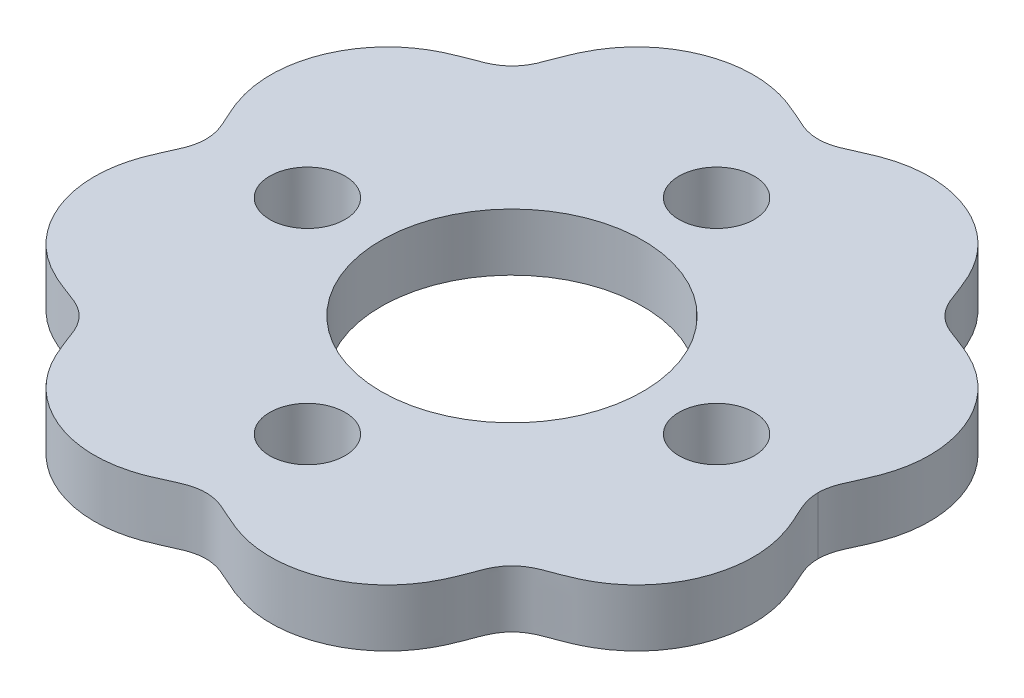
from build123d import *

# Parameters (mm, degrees)
BOSS_EXTRUDE1_DEPTH = 7
SKETCH3_R           = 16
SKETCH3_R_2         = 4.5
CUT_EXTRUDE1_DEPTH  = 7
CUT_EXTRUDE2_DEPTH  = 7
SKETCH5_R           = 4.6
SKETCH5_R_2         = 4.5
CUT_EXTRUDE3_DEPTH  = 7


with BuildPart() as part:
    # Sketch2 → Boss-Extrude1 (new body)
    with BuildSketch(Plane(origin=(0, 0, 0), x_dir=(1, 0, 0), z_dir=(0, 1, 0))):
        with BuildLine():
            add(Edge.make_bspline(
                [(37.500000178, 0), (37.500001348, -0.153650042), (37.516723117, -0.585734713), (37.60134551, -1.155885936), (37.799451038, -1.845132779), (38.055257689, -2.50061582), (38.284413658, -3.01884437), (38.547573645, -3.586057627), (38.834335204, -4.207231283), (39.213023964, -5.071386775), (39.642902809, -6.195484546), (40.034770345, -7.545626157), (40.309114863, -9.129071904), (40.402480997, -10.733442687), (40.292330227, -12.739242447), (39.800709206, -15.115411572), (38.875008006, -17.372282299), (37.550500891, -19.416826213), (36.201869244, -20.937061223), (34.991297456, -22.022332107), (33.664442598, -22.961820777), (32.418877976, -23.648429526), (31.307176029, -24.144813461), (30.415442254, -24.492540623), (29.760772524, -24.733252947), (29.159260868, -24.953726937), (28.615153012, -25.166050116), (27.968227921, -25.455751973), (27.242450172, -25.869161743), (26.486758972, -26.478530797), (25.788934233, -27.338578085), (25.333439826, -28.199550113), (25.02084924, -28.978917238), (24.756184284, -29.69717513), (24.520071708, -30.342148991), (24.176798097, -31.229963234), (23.685673389, -32.343953643), (23.006023391, -33.593318677), (22.074382722, -34.925670234), (20.99628636, -36.142619362), (19.483992231, -37.500137581), (17.436434568, -38.843473511), (15.165772212, -39.787003781), (12.765640508, -40.290729235), (10.727941267, -40.403684264), (9.098120231, -40.306732746), (7.490297544, -40.023060283), (6.12050869, -39.618509318), (4.980859334, -39.175936442), (3.981084292, -38.733166074), (3.107747272, -38.323212218), (2.16284156, -37.896233325), (1.102684883, -37.568652762), (-4e-09, -37.451718585), (-1.102684874, -37.568652759), (-2.162841573, -37.896233332), (-3.107747248, -38.323212203), (-3.981084328, -38.733166098), (-4.980859269, -39.175936398), (-6.120508811, -39.6185094), (-7.490297349, -40.023060149), (-9.098120503, -40.306732933), (-10.727940878, -40.403683996), (-12.765641194, -40.290729708), (-15.165770912, -39.787002885), (-17.436436591, -38.843474905), (-19.48398961, -37.500135775), (-20.996290415, -36.142622155), (-22.074374394, -34.925664496), (-23.006039129, -33.59332952), (-23.685647307, -32.343935674), (-24.176838549, -31.229991103), (-24.570729586, -30.210893235), (-24.899588849, -29.300399238), (-25.267416458, -28.324512461), (-25.788900803, -27.338555053), (-26.486780724, -26.478545782), (-27.242436428, -25.869152274), (-27.968236735, -25.455758045), (-28.615147496, -25.166046316), (-29.159264206, -24.953729236), (-29.760770668, -24.733251668), (-30.415443148, -24.492541238), (-31.307175489, -24.144813089), (-32.41887831, -23.648429756), (-33.6644424, -22.96182064), (-34.99129756, -22.022332179), (-36.201869193, -20.937061188), (-37.550500924, -19.416826235), (-38.875007981, -17.372282282), (-39.800709222, -15.115411584), (-40.292330218, -12.739242441), (-40.402481002, -10.733442691), (-40.309114859, -9.129071901), (-40.034770347, -7.545626159), (-39.642902807, -6.195484545), (-39.213023965, -5.071386776), (-38.834335204, -4.207231283), (-38.547573646, -3.586057627), (-38.284413658, -3.01884437), (-38.055257689, -2.50061582), (-37.799451038, -1.845132779), (-37.60134551, -1.155885936), (-37.516723117, -0.585734713), (-37.500001348, -0.153650042), (-37.500000178, 0)],
                knots=[0.119900748, 0.119900748, 0.119900748, 0.119900748, 0.119900748, 0.123359436, 0.129627259, 0.132815238, 0.136003217, 0.139191195, 0.142379174, 0.14689104, 0.151402906, 0.160426638, 0.169450869, 0.1784751, 0.187499512, 0.196523925, 0.214572937, 0.232831382, 0.241960244, 0.251089107, 0.260218415, 0.269347723, 0.278476117, 0.283040314, 0.287604511, 0.290890352, 0.294176194, 0.297462035, 0.300747877, 0.306837966, 0.312927068, 0.319161334, 0.325493528, 0.328659626, 0.331825723, 0.336390118, 0.340954513, 0.350083302, 0.35921236, 0.368341418, 0.377470301, 0.386599184, 0.404857643, 0.423193135, 0.432360527, 0.441527919, 0.450695565, 0.459863212, 0.469030281, 0.473613816, 0.47819735, 0.484472892, 0.490748434, 0.496943117, 0.503056883, 0.509251566, 0.515527108, 0.52180265, 0.526386184, 0.530969719, 0.540136788, 0.549304435, 0.558472081, 0.567639473, 0.576806865, 0.595142357, 0.613400816, 0.622529699, 0.631658582, 0.64078764, 0.649916698, 0.659045487, 0.663609882, 0.668174277, 0.674506472, 0.680838666, 0.687072932, 0.693162034, 0.699252123, 0.702537965, 0.705823806, 0.709109648, 0.712395489, 0.716959686, 0.721523883, 0.730652277, 0.739781585, 0.748910893, 0.758039756, 0.767168618, 0.785427063, 0.803476075, 0.812500488, 0.8215249, 0.830549131, 0.839573362, 0.848597094, 0.85310896, 0.857620826, 0.860808805, 0.863996783, 0.867184762, 0.870372741, 0.876640564, 0.880099252, 0.880099252, 0.880099252, 0.880099252, 0.880099252], degree=4))
            add(Edge.make_bspline(
                [(37.500000178, 0), (37.500001348, 0.153650042), (37.516723117, 0.585734713), (37.60134551, 1.155885936), (37.799451038, 1.845132779), (38.055257689, 2.50061582), (38.284413658, 3.018844371), (38.547573645, 3.586057627), (38.834335204, 4.207231284), (39.213023964, 5.071386775), (39.642902809, 6.195484546), (40.034770345, 7.545626157), (40.309114863, 9.129071904), (40.402480997, 10.733442688), (40.292330227, 12.739242447), (39.800709205, 15.115411572), (38.875008006, 17.3722823), (37.550500891, 19.416826213), (36.201869244, 20.937061223), (34.991297456, 22.022332107), (33.664442598, 22.961820777), (32.418877976, 23.648429526), (31.307176029, 24.144813461), (30.415442254, 24.492540623), (29.760772524, 24.733252947), (29.159260868, 24.953726937), (28.615153012, 25.166050117), (27.968227921, 25.455751974), (27.242450172, 25.869161744), (26.486758972, 26.478530797), (25.788934233, 27.338578085), (25.333439826, 28.199550113), (25.02084924, 28.978917238), (24.756184284, 29.69717513), (24.520071708, 30.342148991), (24.176798097, 31.229963234), (23.685673389, 32.343953643), (23.006023391, 33.593318677), (22.074382722, 34.925670234), (20.99628636, 36.142619362), (19.483992231, 37.500137582), (17.436434568, 38.843473511), (15.165772212, 39.787003781), (12.765640508, 40.290729235), (10.727941267, 40.403684265), (9.098120231, 40.306732746), (7.490297544, 40.023060283), (6.12050869, 39.618509318), (4.980859334, 39.175936443), (3.981084292, 38.733166074), (3.107747271, 38.323212218), (2.162841559, 37.896233325), (1.102684882, 37.568652762), (-4e-09, 37.451718586), (-1.102684874, 37.568652759), (-2.162841573, 37.896233332), (-3.107747248, 38.323212203), (-3.981084328, 38.733166098), (-4.980859269, 39.175936399), (-6.120508811, 39.6185094), (-7.490297349, 40.023060149), (-9.098120503, 40.306732933), (-10.727940878, 40.403683996), (-12.765641194, 40.290729708), (-15.165770912, 39.787002885), (-17.436436591, 38.843474905), (-19.48398961, 37.500135776), (-20.996290415, 36.142622155), (-22.074374394, 34.925664496), (-23.006039129, 33.59332952), (-23.685647307, 32.343935674), (-24.176838549, 31.229991103), (-24.570729586, 30.210893235), (-24.899588849, 29.300399238), (-25.267416458, 28.324512461), (-25.788900803, 27.338555053), (-26.486780724, 26.478545782), (-27.242436428, 25.869152274), (-27.968236735, 25.455758045), (-28.615147496, 25.166046316), (-29.159264206, 24.953729236), (-29.760770668, 24.733251668), (-30.415443148, 24.492541238), (-31.307175489, 24.144813089), (-32.418878311, 23.648429756), (-33.6644424, 22.96182064), (-34.99129756, 22.022332179), (-36.201869193, 20.937061188), (-37.550500924, 19.416826235), (-38.875007981, 17.372282282), (-39.800709222, 15.115411584), (-40.292330218, 12.739242441), (-40.402481002, 10.733442691), (-40.309114859, 9.129071901), (-40.034770347, 7.545626159), (-39.642902807, 6.195484545), (-39.213023965, 5.071386776), (-38.834335204, 4.207231283), (-38.547573646, 3.586057627), (-38.284413658, 3.01884437), (-38.055257689, 2.50061582), (-37.799451038, 1.845132779), (-37.60134551, 1.155885936), (-37.516723117, 0.585734713), (-37.500001348, 0.153650042), (-37.500000178, 0)],
                knots=[0.119900748, 0.119900748, 0.119900748, 0.119900748, 0.119900748, 0.123359436, 0.129627259, 0.132815238, 0.136003217, 0.139191195, 0.142379174, 0.14689104, 0.151402906, 0.160426638, 0.169450869, 0.1784751, 0.187499512, 0.196523925, 0.214572937, 0.232831382, 0.241960244, 0.251089107, 0.260218415, 0.269347723, 0.278476117, 0.283040314, 0.287604511, 0.290890352, 0.294176194, 0.297462035, 0.300747877, 0.306837966, 0.312927068, 0.319161334, 0.325493528, 0.328659626, 0.331825723, 0.336390118, 0.340954513, 0.350083302, 0.35921236, 0.368341418, 0.377470301, 0.386599184, 0.404857643, 0.423193135, 0.432360527, 0.441527919, 0.450695565, 0.459863212, 0.469030281, 0.473613816, 0.47819735, 0.484472892, 0.490748434, 0.496943117, 0.503056883, 0.509251566, 0.515527108, 0.52180265, 0.526386184, 0.530969719, 0.540136788, 0.549304435, 0.558472081, 0.567639473, 0.576806865, 0.595142357, 0.613400816, 0.622529699, 0.631658582, 0.64078764, 0.649916698, 0.659045487, 0.663609882, 0.668174277, 0.674506472, 0.680838666, 0.687072932, 0.693162034, 0.699252123, 0.702537965, 0.705823806, 0.709109648, 0.712395489, 0.716959686, 0.721523883, 0.730652277, 0.739781585, 0.748910893, 0.758039756, 0.767168618, 0.785427063, 0.803476075, 0.812500488, 0.8215249, 0.830549131, 0.839573362, 0.848597094, 0.85310896, 0.857620826, 0.860808805, 0.863996783, 0.867184762, 0.870372741, 0.876640564, 0.880099252, 0.880099252, 0.880099252, 0.880099252, 0.880099252], degree=4))
        make_face()
    extrude(amount=BOSS_EXTRUDE1_DEPTH)

    # Sketch3 → Cut-Extrude1 (cut)
    with BuildSketch(Plane(origin=(0, 7, 0), x_dir=(1, 0, 0), z_dir=(0, 1, 0))):
        with Locations(Location((0, 0, 0), (0, 0, 270))):
            Circle(SKETCH3_R)
        with Locations(Location((25, 0, 0), (0, 0, 270))):
            Circle(SKETCH3_R_2)
        with Locations(Location((0, -25, 0), (0, 0, 270))):
            Circle(SKETCH3_R_2)
        with Locations(Location((-25, 0, 0), (0, 0, 270))):
            Circle(SKETCH3_R_2)
        with Locations(Location((0, 25, 0), (0, 0, 270))):
            Circle(SKETCH3_R_2)
    extrude(amount=-CUT_EXTRUDE1_DEPTH, mode=Mode.SUBTRACT)

    # Sketch4 → Cut-Extrude2 (cut)
    with BuildSketch(Plane.XZ):
        with BuildLine():
            add(Edge.make_bspline(
                [(37.600000178, -7.62e-07), (37.600005173, 0.655543434), (37.727246294, 1.285292151), (38.148613998, 2.510955716), (38.436102386, 3.105161712), (38.985288009, 4.298020071), (39.25007046, 4.89726072), (39.708668965, 6.116079685), (39.903757651, 6.735293288), (40.210295805, 7.997689961), (40.322350501, 8.640699582), (40.423535505, 9.624385479), (40.446121573, 9.955473947), (40.468001099, 10.624326117), (40.467132418, 10.962202585), (40.404154621, 12.633267942), (40.171207894, 13.940406977), (39.653355411, 15.537439287), (39.53840444, 15.854111127), (39.288969244, 16.474140513), (39.154125231, 16.778652945), (38.719700075, 17.675947604), (38.390382228, 18.252572177), (37.651152224, 19.362029827), (37.237638616, 19.898295795), (36.350233191, 20.896017325), (35.875310831, 21.360215751), (34.86364689, 22.219976378), (34.326804277, 22.615426405), (33.190062483, 23.336316439), (32.60031159, 23.654622118), (31.388326763, 24.220411489), (30.765097907, 24.46709151), (29.82114865, 24.818166657), (29.504943402, 24.932139267), (28.877738152, 25.170299043), (28.566999308, 25.294998698), (27.963605007, 25.579884088), (27.671054253, 25.740275293), (27.252684988, 26.021005802), (27.116605528, 26.121209448), (26.852062793, 26.336562421), (26.722665603, 26.452707189), (26.356285675, 26.816433091), (26.140022275, 27.07952826), (25.757076777, 27.642229352), (25.590264073, 27.942868865), (25.294527671, 28.566753755), (25.165960187, 28.88852981), (24.920043824, 29.537797739), (24.802144961, 29.865009399), (24.438030972, 30.841336769), (24.180422964, 31.484647868), (23.587360405, 32.731607676), (23.25304691, 33.335837747), (22.68412998, 34.207819134), (22.483367041, 34.492811998), (22.058499308, 35.050905177), (21.833191694, 35.325295896), (20.664259321, 36.645203337), (19.595247471, 37.543032975), (18.094714825, 38.471318944), (17.786587006, 38.646710961), (17.16359185, 38.972125312), (16.847523582, 39.122917749), (15.885856655, 39.540202403), (15.22687273, 39.771802315), (13.87261568, 40.140404542), (13.173528063, 40.277153852), (11.782084832, 40.445055871), (11.084941822, 40.478018046), (10.037091008, 40.450827085), (9.687449992, 40.428942237), (8.987437718, 40.358977003), (8.635705971, 40.310604168), (7.593654297, 40.127900907), (6.914470746, 39.955864647), (5.583322024, 39.523679687), (4.931756901, 39.262235939), (3.965705794, 38.833500579), (3.645753433, 38.684780069), (3.005286176, 38.389391142), (2.68471998, 38.242500373), (2.031257787, 37.978515382), (1.696459255, 37.861664089), (1.010367338, 37.687113144), (0.664117722, 37.630625011), (-0.035741815, 37.588381702), (-0.393307149, 37.603289467), (-1.091614861, 37.702477523), (-1.432710085, 37.785974847), (-2.438166569, 38.111475608), (-3.083100648, 38.4262163), (-4.379716439, 39.022574646), (-5.031837648, 39.307994347), (-7.027326378, 40.033339578), (-8.409077537, 40.344832204), (-10.21846616, 40.459155192), (-10.584845551, 40.468254818), (-11.309896166, 40.458614645), (-11.670551949, 40.440062156), (-12.747048154, 40.344216969), (-13.457448828, 40.226967163), (-14.86370086, 39.885597037), (-15.562456431, 39.659406696), (-16.900219943, 39.113501325), (-17.544817785, 38.792942013), (-18.475327327, 38.240768871), (-18.779405529, 38.044768985), (-19.375039214, 37.628219448), (-19.66690843, 37.407240978), (-20.508686277, 36.71835058), (-21.030063876, 36.221285174), (-21.994225641, 35.152514509), (-22.437469885, 34.579790659), (-23.240332907, 33.36091442), (-23.59210782, 32.725699772), (-24.21279859, 31.412258693), (-24.48008686, 30.732790864), (-24.860030442, 29.706920221), (-24.983492598, 29.36369043), (-25.247586749, 28.684091392), (-25.389357526, 28.348177168), (-25.724856238, 27.697109221), (-25.915605335, 27.388429681), (-26.246180912, 26.958382913), (-26.363678476, 26.820434816), (-26.614172398, 26.555996288), (-26.747939886, 26.428953409), (-27.16370152, 26.07353653), (-27.462129542, 25.868655053), (-28.093141458, 25.510419531), (-28.426355493, 25.357147124), (-29.105776125, 25.079258707), (-29.452106763, 24.953195271), (-30.14359664, 24.698789273), (-30.488894925, 24.570717247), (-31.514041104, 24.165588103), (-32.18271169, 23.866783955), (-33.471088526, 23.173908637), (-34.091529712, 22.781267386), (-34.981950491, 22.114010966), (-35.27336833, 21.877454907), (-35.835818537, 21.382587609), (-36.105593168, 21.125601748), (-36.881608687, 20.326857649), (-37.354731828, 19.757471925), (-37.998824092, 18.848674808), (-38.202543253, 18.53658415), (-38.587532455, 17.893675331), (-38.767696262, 17.564496513), (-39.266089097, 16.565119922), (-39.545090734, 15.87888218), (-39.884673796, 14.819909921), (-39.984652036, 14.461959629), (-40.157555715, 13.735907091), (-40.230632334, 13.366355214), (-40.521494844, 11.52176003), (-40.525439669, 10.040086765), (-40.178392425, 7.814366715), (-40.005185357, 7.088457072), (-39.55623337, 5.665152555), (-39.278423148, 4.967801646), (-38.820443408, 3.936514094), (-38.661078223, 3.595018652), (-38.346103028, 2.91075813), (-38.190776414, 2.567897234), (-37.919747303, 1.868778393), (-37.804834772, 1.512253359), (-37.645169711, 0.77548196), (-37.60000319, 0.395375566), (-37.600000178, -7.62e-07)],
                knots=[0, 0, 0, 0, 0.015625, 0.015625, 0.03125, 0.03125, 0.046875, 0.046875, 0.0625, 0.0625, 0.078125, 0.078125, 0.0859375, 0.0859375, 0.09375, 0.09375, 0.125, 0.125, 0.1328125, 0.1328125, 0.140625, 0.140625, 0.15625, 0.15625, 0.171875, 0.171875, 0.1875, 0.1875, 0.203125, 0.203125, 0.21875, 0.21875, 0.234375, 0.234375, 0.2421875, 0.2421875, 0.25, 0.25, 0.2578125, 0.2578125, 0.26171875, 0.26171875, 0.265625, 0.265625, 0.2734375, 0.2734375, 0.28125, 0.28125, 0.2890625, 0.2890625, 0.296875, 0.296875, 0.3125, 0.3125, 0.328125, 0.328125, 0.3359375, 0.3359375, 0.34375, 0.34375, 0.375, 0.375, 0.3828125, 0.3828125, 0.390625, 0.390625, 0.40625, 0.40625, 0.421875, 0.421875, 0.4375, 0.4375, 0.4453125, 0.4453125, 0.453125, 0.453125, 0.46875, 0.46875, 0.484375, 0.484375, 0.4921875, 0.4921875, 0.5, 0.5, 0.5078125, 0.5078125, 0.515625, 0.515625, 0.5234375, 0.5234375, 0.53125, 0.53125, 0.546875, 0.546875, 0.5625, 0.5625, 0.59375, 0.59375, 0.6015625, 0.6015625, 0.609375, 0.609375, 0.625, 0.625, 0.640625, 0.640625, 0.65625, 0.65625, 0.6640625, 0.6640625, 0.671875, 0.671875, 0.6875, 0.6875, 0.703125, 0.703125, 0.71875, 0.71875, 0.734375, 0.734375, 0.7421875, 0.7421875, 0.75, 0.75, 0.7578125, 0.7578125, 0.76171875, 0.76171875, 0.765625, 0.765625, 0.7734375, 0.7734375, 0.78125, 0.78125, 0.7890625, 0.7890625, 0.796875, 0.796875, 0.8125, 0.8125, 0.828125, 0.828125, 0.8359375, 0.8359375, 0.84375, 0.84375, 0.859375, 0.859375, 0.8671875, 0.8671875, 0.875, 0.875, 0.890625, 0.890625, 0.8984375, 0.8984375, 0.90625, 0.90625, 0.9375, 0.9375, 0.953125, 0.953125, 0.96875, 0.96875, 0.9765625, 0.9765625, 0.984375, 0.984375, 0.9921875, 0.9921875, 1, 1, 1, 1], degree=3))
            add(Edge.make_bspline(
                [(-37.600000178, -7.62e-07), (-37.600005365, -0.655543542), (-37.727246103, -1.285290917), (-38.148612441, -2.510951863), (-38.436099991, -3.105156631), (-38.985284513, -4.298012358), (-39.250066616, -4.89725163), (-39.708664877, -6.116067692), (-39.903753667, -6.73527977), (-40.210292449, -7.99767325), (-40.32234767, -8.640681203), (-40.423533815, -9.624364479), (-40.446120322, -9.955452053), (-40.46800086, -10.624302393), (-40.467132754, -10.962178241), (-40.40415798, -12.633240584), (-40.171214287, -13.940377214), (-39.653366826, -15.537406602), (-39.538416782, -15.85407826), (-39.288983549, -16.474107134), (-39.154140553, -16.778619323), (-38.719718579, -17.675913303), (-38.390403025, -18.252537492), (-37.651178052, -19.361994563), (-37.237667074, -19.898260544), (-36.350266394, -20.895983208), (-35.875346564, -21.360182341), (-34.863687943, -22.2199446), (-34.326848086, -22.615395516), (-33.190112346, -23.336287858), (-32.600363206, -23.654595622), (-31.388382903, -24.22038754), (-30.765156596, -24.467069397), (-29.821209522, -24.818143642), (-29.505006095, -24.932118144), (-28.877800637, -25.170273989), (-28.567061614, -25.294971441), (-27.963668625, -25.579855149), (-27.671114267, -25.740236871), (-27.252743788, -26.020960746), (-27.116664699, -26.121163599), (-26.852122749, -26.336514839), (-26.722725603, -26.452657923), (-26.356336634, -26.81637785), (-26.140060384, -27.079462774), (-25.757116549, -27.642161336), (-25.590319291, -27.94280622), (-25.294558985, -28.566675929), (-25.165952551, -28.888431272), (-24.920089484, -29.537724991), (-24.802198315, -29.864940055), (-24.438006248, -30.841225751), (-24.180470786, -31.484572065), (-23.587393761, -32.73151845), (-23.253098655, -33.335753624), (-22.684194198, -34.207732752), (-22.483432874, -34.492723202), (-22.058571, -35.050812128), (-21.833267652, -35.325202016), (-20.664333278, -36.645139912), (-19.59532023, -37.542975085), (-18.094804652, -38.471266211), (-17.786672933, -38.646663689), (-17.163673089, -38.97208582), (-16.847603026, -39.122881412), (-15.885932573, -39.540174), (-15.226948812, -39.771777283), (-13.872698563, -40.140385932), (-13.173607801, -40.277140714), (-11.782152302, -40.445051479), (-11.085006279, -40.478016471), (-10.037155717, -40.4508303), (-9.687515582, -40.428947116), (-8.987506709, -40.358985611), (-8.635775999, -40.310614821), (-7.593711021, -40.127914145), (-6.914521606, -39.955878883), (-5.583365941, -39.523696233), (-4.931799795, -39.262253844), (-3.965749214, -38.833520414), (-3.645796202, -38.68479995), (-3.005328478, -38.389410498), (-2.684762254, -38.242519007), (-2.031301111, -37.978531327), (-1.696505827, -37.861678656), (-1.0104107, -37.687121458), (-0.664160249, -37.630630436), (0.035699138, -37.588381419), (0.393263445, -37.60328603), (1.091574708, -37.702469051), (1.432671198, -37.785964254), (2.438130273, -38.111459865), (3.083065306, -38.426199691), (4.379682535, -39.022559402), (5.031804119, -39.307980643), (7.027293072, -40.033330486), (8.409043202, -40.344826141), (10.218428372, -40.459153805), (10.584809331, -40.468254499), (11.309863139, -40.458615982), (11.670520298, -40.44006415), (12.747020041, -40.344220841), (13.45742231, -40.226972298), (14.863675994, -39.885604677), (15.562434158, -39.659414723), (16.900203227, -39.113508859), (17.54480309, -38.792949489), (18.475314811, -38.240777102), (18.77939358, -38.044777578), (19.37502788, -37.628228605), (19.666898392, -37.407249287), (20.508679462, -36.718355349), (21.030059241, -36.221288774), (21.994226396, -35.15251904), (22.437464112, -34.579791894), (23.240331243, -33.360911439), (23.592120209, -32.725702161), (24.212786306, -31.412246514), (24.480142321, -30.732808794), (24.859989324, -29.706902419), (24.983506975, -29.363695738), (25.24761708, -28.684105036), (25.389343463, -28.348174104), (25.724844079, -27.697109244), (25.91561204, -27.388436226), (26.246183235, -26.958387021), (26.363676717, -26.820436861), (26.614164843, -26.55599741), (26.747931978, -26.428954455), (27.163699633, -26.073538663), (27.462129817, -25.868658916), (28.093136327, -25.510418282), (28.426351029, -25.357151397), (29.10577059, -25.079261698), (29.452100801, -24.953197072), (30.143591533, -24.698792161), (30.488889356, -24.570718998), (31.514035603, -24.165590501), (32.18270537, -23.866786785), (33.471078721, -23.173914326), (34.091517278, -22.781275489), (34.981932843, -22.114024813), (35.273346468, -21.877473279), (35.83580515, -21.382600187), (36.105583092, -21.125611724), (36.88160624, -20.326861011), (37.354731418, -19.757472462), (37.998823996, -18.848674943), (38.202542797, -18.536584789), (38.587530614, -17.893678518), (38.767698421, -17.564492662), (39.266095867, -16.565105414), (39.545098068, -15.878862979), (39.884680234, -14.819888), (39.98465788, -14.461937524), (40.157560102, -13.735886218), (40.230636486, -13.366333326), (40.521499132, -11.52171509), (40.525439935, -10.040058501), (40.178382099, -7.81431547), (40.005171366, -7.08840487), (39.556217128, -5.665108908), (39.278408813, -4.96776748), (38.820430227, -3.936485358), (38.661065563, -3.594991484), (38.346092068, -2.910733985), (38.190766712, -2.567874525), (37.919740862, -1.868759462), (37.804830308, -1.5122368), (37.64516852, -0.775472421), (37.600003306, -0.395370659), (37.600000178, -7.62e-07)],
                knots=[0, 0, 0, 0, 0.015625, 0.015625, 0.03125, 0.03125, 0.046875, 0.046875, 0.0625, 0.0625, 0.078125, 0.078125, 0.0859375, 0.0859375, 0.09375, 0.09375, 0.125, 0.125, 0.1328125, 0.1328125, 0.140625, 0.140625, 0.15625, 0.15625, 0.171875, 0.171875, 0.1875, 0.1875, 0.203125, 0.203125, 0.21875, 0.21875, 0.234375, 0.234375, 0.2421875, 0.2421875, 0.25, 0.25, 0.2578125, 0.2578125, 0.26171875, 0.26171875, 0.265625, 0.265625, 0.2734375, 0.2734375, 0.28125, 0.28125, 0.2890625, 0.2890625, 0.296875, 0.296875, 0.3125, 0.3125, 0.328125, 0.328125, 0.3359375, 0.3359375, 0.34375, 0.34375, 0.375, 0.375, 0.3828125, 0.3828125, 0.390625, 0.390625, 0.40625, 0.40625, 0.421875, 0.421875, 0.4375, 0.4375, 0.4453125, 0.4453125, 0.453125, 0.453125, 0.46875, 0.46875, 0.484375, 0.484375, 0.4921875, 0.4921875, 0.5, 0.5, 0.5078125, 0.5078125, 0.515625, 0.515625, 0.5234375, 0.5234375, 0.53125, 0.53125, 0.546875, 0.546875, 0.5625, 0.5625, 0.59375, 0.59375, 0.6015625, 0.6015625, 0.609375, 0.609375, 0.625, 0.625, 0.640625, 0.640625, 0.65625, 0.65625, 0.6640625, 0.6640625, 0.671875, 0.671875, 0.6875, 0.6875, 0.703125, 0.703125, 0.71875, 0.71875, 0.734375, 0.734375, 0.7421875, 0.7421875, 0.75, 0.75, 0.7578125, 0.7578125, 0.76171875, 0.76171875, 0.765625, 0.765625, 0.7734375, 0.7734375, 0.78125, 0.78125, 0.7890625, 0.7890625, 0.796875, 0.796875, 0.8125, 0.8125, 0.828125, 0.828125, 0.8359375, 0.8359375, 0.84375, 0.84375, 0.859375, 0.859375, 0.8671875, 0.8671875, 0.875, 0.875, 0.890625, 0.890625, 0.8984375, 0.8984375, 0.90625, 0.90625, 0.9375, 0.9375, 0.953125, 0.953125, 0.96875, 0.96875, 0.9765625, 0.9765625, 0.984375, 0.984375, 0.9921875, 0.9921875, 1, 1, 1, 1], degree=3))
        make_face()
        with BuildLine():
            add(Edge.make_bspline(
                [(-37.400000178, -7.62e-07), (-37.400005396, -0.684782698), (-37.533286812, -1.339126969), (-37.971679468, -2.608572955), (-38.271031887, -3.223687862), (-38.838782813, -4.459321056), (-39.110829218, -5.081035786), (-39.576516793, -6.350302799), (-39.771486208, -6.997417375), (-39.99451977, -7.990965997), (-40.05744554, -8.32591179), (-40.159277451, -9.003718774), (-40.198243708, -9.348068689), (-40.276348787, -10.376291039), (-40.277850295, -11.058613953), (-40.183363174, -12.417170278), (-40.087400677, -13.09340532), (-39.868679486, -14.103087076), (-39.783319969, -14.438056838), (-39.59042803, -15.095859731), (-39.48263265, -15.419986744), (-39.12581691, -16.378304723), (-38.84355357, -16.998511139), (-38.18898741, -18.201046447), (-37.813942623, -18.785938211), (-36.99479459, -19.880772476), (-36.548792021, -20.3951967), (-35.82505198, -21.117259116), (-35.574649061, -21.349653891), (-35.055120881, -21.797486837), (-34.784834447, -22.013734698), (-33.955457842, -22.628774327), (-33.377932351, -22.994173963), (-32.178507652, -23.644500379), (-31.556012432, -23.928346277), (-30.599954922, -24.313646888), (-30.277766915, -24.435469134), (-29.63193924, -24.674412462), (-29.307914732, -24.791237357), (-28.665975068, -25.039445958), (-28.348334449, -25.171483897), (-27.730650697, -25.477495242), (-27.428442172, -25.653477659), (-26.868187016, -26.052195413), (-26.608446968, -26.274990584), (-26.132348562, -26.770449944), (-25.915011101, -27.045671206), (-25.537300003, -27.621849778), (-25.211954314, -28.227622351), (-24.957163129, -28.873297255), (-24.712468595, -29.523337971), (-24.594494769, -29.850537878), (-24.350947641, -30.501150415), (-24.225635279, -30.824693088), (-23.827233466, -31.784125578), (-23.530975212, -32.408468985), (-22.85017451, -33.613158464), (-22.466684316, -34.194028938), (-21.603070624, -35.307611687), (-21.132656874, -35.827766741), (-20.125777301, -36.788678712), (-19.58809831, -37.231085461), (-18.729810076, -37.837165058), (-18.433783397, -38.030294514), (-17.831109532, -38.392526944), (-17.524735048, -38.561626533), (-16.590894916, -39.033819984), (-15.94879626, -39.302008124), (-14.956328158, -39.634349833), (-14.62059786, -39.733423772), (-13.939053544, -39.907517841), (-13.593789054, -39.982265156), (-12.559820995, -40.166656604), (-11.8674468, -40.238150222), (-10.476620435, -40.279047706), (-9.776594528, -40.248219137), (-8.376672719, -40.079878197), (-7.6911699, -39.944036586), (-6.346580769, -39.577944521), (-5.687826974, -39.346505701), (-4.714282748, -38.947217509), (-4.392074109, -38.805607303), (-3.751381616, -38.514617754), (-3.432753161, -38.36487402), (-2.792036452, -38.073944369), (-2.469758023, -37.933228846), (-1.809689185, -37.690166697), (-1.469545671, -37.587394011), (-0.775270684, -37.444719036), (-0.426808853, -37.405549185), (0.09799503, -37.398073089), (0.273279678, -37.404082921), (0.624554464, -37.433238656), (0.801546504, -37.456601741), (1.325077342, -37.550476286), (1.66339974, -37.644392915), (2.325478044, -37.874889644), (2.649203286, -38.011559554), (3.2917588, -38.299236139), (3.610903594, -38.449412827), (4.251521045, -38.742650641), (4.572846355, -38.886011923), (5.544255336, -39.292276704), (6.202012957, -39.530589187), (7.547443713, -39.911350487), (8.23472814, -40.055044912), (9.29000814, -40.1925467), (9.6461978, -40.225289386), (10.353430535, -40.263373674), (10.706125957, -40.268992909), (11.761511932, -40.246493479), (12.461516923, -40.179232376), (13.854352603, -39.940143682), (14.550375034, -39.766491039), (15.891060177, -39.324781027), (16.54105071, -39.056315832), (17.485676754, -38.582596479), (17.795469882, -38.412801026), (18.404639621, -38.048842421), (18.704595381, -37.854141796), (20.153495888, -36.834999859), (21.171952529, -35.866147091), (22.481006654, -34.174225043), (22.869476355, -33.583405835), (23.558708325, -32.354697774), (23.85844027, -31.71587745), (24.262128264, -30.732621462), (24.389246226, -30.40070898), (24.63692668, -29.734586129), (24.757334626, -29.400089263), (25.010944677, -28.736446272), (25.144925475, -28.40762581), (25.456484559, -27.76821812), (25.635968748, -27.455381634), (26.045030072, -26.876026075), (26.27464328, -26.60771406), (26.78766381, -26.116912824), (27.072701132, -25.894410351), (27.669080144, -25.509607724), (27.983173611, -25.344568468), (28.632231292, -25.05039715), (28.966685454, -24.920989432), (29.638938436, -24.670249034), (29.976782523, -24.548266438), (30.64756686, -24.294629444), (30.980672328, -24.163300906), (31.967133586, -23.74396118), (32.607250079, -23.429838227), (33.839298887, -22.706559031), (34.431789218, -22.298503359), (35.564278995, -21.378864634), (36.089123563, -20.879663569), (37.054138637, -19.811388989), (37.495362926, -19.241503897), (38.094449592, -18.33234027), (38.284134766, -18.019119802), (38.63632304, -17.38438218), (38.799558141, -17.061911954), (39.251551291, -16.079540171), (39.502830049, -15.404769892), (39.904118336, -14.015053973), (40.053893907, -13.295882593), (40.239714572, -11.86329121), (40.277796435, -11.144821741), (40.252251475, -10.06384002), (40.229900275, -9.702964217), (40.156824934, -8.980087712), (40.105861118, -8.617487518), (39.913081657, -7.546146616), (39.730522673, -6.848033091), (39.27169922, -5.47974765), (38.993704358, -4.80981043), (38.544415856, -3.815458247), (38.389526399, -3.485950632), (38.087864961, -2.823858685), (37.941658479, -2.491060014), (37.689775713, -1.81010075), (37.58446697, -1.461800851), (37.439017725, -0.740500718), (37.400003001, -0.370486849), (37.400000178, -7.62e-07)],
                knots=[0, 0, 0, 0, 0.015625, 0.015625, 0.03125, 0.03125, 0.046875, 0.046875, 0.0625, 0.0625, 0.0703125, 0.0703125, 0.078125, 0.078125, 0.09375, 0.09375, 0.109375, 0.109375, 0.1171875, 0.1171875, 0.125, 0.125, 0.140625, 0.140625, 0.15625, 0.15625, 0.171875, 0.171875, 0.1796875, 0.1796875, 0.1875, 0.1875, 0.203125, 0.203125, 0.21875, 0.21875, 0.2265625, 0.2265625, 0.234375, 0.234375, 0.2421875, 0.2421875, 0.25, 0.25, 0.2578125, 0.2578125, 0.265625, 0.265625, 0.2734375, 0.28125, 0.28125, 0.2890625, 0.2890625, 0.296875, 0.296875, 0.3125, 0.3125, 0.328125, 0.328125, 0.34375, 0.34375, 0.359375, 0.359375, 0.3671875, 0.3671875, 0.375, 0.375, 0.390625, 0.390625, 0.3984375, 0.3984375, 0.40625, 0.40625, 0.421875, 0.421875, 0.4375, 0.4375, 0.453125, 0.453125, 0.46875, 0.46875, 0.4765625, 0.4765625, 0.484375, 0.484375, 0.4921875, 0.4921875, 0.5, 0.5, 0.5078125, 0.5078125, 0.51171875, 0.51171875, 0.515625, 0.515625, 0.5234375, 0.5234375, 0.53125, 0.53125, 0.5390625, 0.5390625, 0.546875, 0.546875, 0.5625, 0.5625, 0.578125, 0.578125, 0.5859375, 0.5859375, 0.59375, 0.59375, 0.609375, 0.609375, 0.625, 0.625, 0.640625, 0.640625, 0.6484375, 0.6484375, 0.65625, 0.65625, 0.6875, 0.6875, 0.703125, 0.703125, 0.71875, 0.71875, 0.7265625, 0.7265625, 0.734375, 0.734375, 0.7421875, 0.7421875, 0.75, 0.75, 0.7578125, 0.7578125, 0.765625, 0.765625, 0.7734375, 0.7734375, 0.78125, 0.78125, 0.7890625, 0.7890625, 0.796875, 0.796875, 0.8125, 0.8125, 0.828125, 0.828125, 0.84375, 0.84375, 0.859375, 0.859375, 0.8671875, 0.8671875, 0.875, 0.875, 0.890625, 0.890625, 0.90625, 0.90625, 0.921875, 0.921875, 0.9296875, 0.9296875, 0.9375, 0.9375, 0.953125, 0.953125, 0.96875, 0.96875, 0.9765625, 0.9765625, 0.984375, 0.984375, 0.9921875, 0.9921875, 1, 1, 1, 1], degree=3))
            add(Edge.make_bspline(
                [(37.400000178, -7.62e-07), (37.400005211, 0.660526746), (37.523977501, 1.29540216), (37.939463583, 2.530484232), (38.226257408, 3.128635327), (38.778794095, 4.326812562), (39.046689823, 4.928593245), (39.511066322, 6.155116822), (39.708851207, 6.779440402), (40.018395071, 8.055747664), (40.130807725, 8.707521169), (40.229547684, 9.707649786), (40.250562149, 10.043364738), (40.268565113, 10.709956622), (40.265707653, 11.042219869), (40.222296367, 12.035975783), (40.147077487, 12.694449763), (39.904068767, 14.003336498), (39.734463367, 14.65767644), (39.311302811, 15.920724052), (39.057601567, 16.533285026), (38.467026075, 17.720962541), (38.128960459, 18.297833786), (36.991087238, 19.958165857), (36.096609023, 20.9355039), (34.808398042, 21.995007177), (34.540971479, 22.199442547), (33.994593718, 22.587114403), (33.716070811, 22.770173128), (32.865357571, 23.288750355), (32.277681039, 23.59297956), (31.069813356, 24.135743375), (30.448975387, 24.372971111), (29.200201148, 24.833084729), (28.571398097, 25.055378024), (27.689823042, 25.500931582), (27.406297701, 25.668262692), (27.002004464, 25.957484431), (26.870709842, 26.060209106), (26.615761594, 26.279570377), (26.492546943, 26.396003166), (26.144518051, 26.757006015), (25.937915668, 27.016214298), (25.569824446, 27.56753783), (25.408434568, 27.860034493), (25.119553876, 28.468463651), (24.992898714, 28.782481031), (24.751370288, 29.417009712), (24.635885133, 29.737183752), (24.280743093, 30.692918025), (24.031231621, 31.323046628), (23.173565964, 33.153281708), (22.457000074, 34.29363405), (21.332873203, 35.593174697), (21.095937952, 35.847709425), (20.602097749, 36.339970183), (20.347545797, 36.575480681), (19.561733249, 37.251180669), (19.00843333, 37.660701973), (18.135116869, 38.214638409), (17.836754202, 38.389185368), (17.225266154, 38.717736656), (16.911016534, 38.872169969), (15.959892482, 39.297507436), (15.311556823, 39.53274301), (13.987071128, 39.908913257), (13.310924966, 40.049861066), (12.27487819, 40.187279465), (11.927463383, 40.22038702), (11.236307511, 40.260798556), (10.891406325, 40.268263692), (9.858709485, 40.252880281), (9.172916312, 40.192332631), (7.806730359, 39.969568502), (7.124378456, 39.805541912), (5.800093078, 39.390296879), (5.153992218, 39.137525071), (4.198608276, 38.719619539), (3.882389418, 38.574020508), (3.250188311, 38.28192442), (2.934318288, 38.13518087), (1.975047783, 37.730129407), (1.317424762, 37.514730452), (0.439198977, 37.415026414), (0.259708055, 37.40334246), (-0.095412931, 37.397941183), (-0.271877491, 37.404019401), (-0.798114637, 37.447539123), (-1.144689359, 37.510596784), (-1.830567935, 37.694954626), (-2.168027999, 37.815976793), (-2.829766579, 38.087947759), (-3.155853923, 38.238413534), (-4.134006506, 38.690142284), (-4.78689459, 38.988913588), (-6.120679737, 39.501641728), (-6.800796642, 39.717960977), (-7.84644406, 39.965307465), (-8.199161151, 40.03513525), (-8.913404674, 40.1481151), (-9.276683745, 40.191404426), (-11.093467358, 40.336028285), (-12.530824776, 40.227808083), (-14.307825155, 39.818074396), (-14.660524996, 39.72238611), (-15.352537408, 39.50631918), (-15.693088857, 39.385665114), (-16.698649417, 38.986466941), (-17.347667018, 38.670923485), (-18.288393957, 38.121720617), (-18.597730413, 37.925015906), (-19.196446731, 37.511267489), (-19.486294201, 37.294105766), (-20.327804097, 36.61229841), (-20.851579511, 36.117487978), (-21.823512792, 35.046073189), (-22.274063205, 34.464440408), (-23.071551157, 33.253414062), (-23.421069873, 32.621310949), (-24.037803881, 31.312646997), (-24.303433863, 30.634666583), (-24.809009203, 29.268029237), (-25.045683547, 28.577980712), (-25.547797074, 27.604346189), (-25.741150791, 27.290253622), (-26.18007317, 26.713395984), (-26.426501859, 26.447670854), (-26.839152243, 26.085290648), (-26.983661391, 25.970845431), (-27.280023154, 25.758360658), (-27.432640183, 25.659631485), (-27.902166961, 25.383218313), (-28.231137337, 25.225717546), (-28.906529551, 24.941298997), (-29.25179389, 24.813842729), (-29.94264379, 24.559556365), (-30.288221739, 24.432711428), (-31.314945512, 24.032663647), (-31.985642045, 23.739091649), (-33.277973663, 23.056310529), (-33.900370733, 22.66858677), (-34.793385788, 22.007896108), (-35.08563534, 21.773402141), (-35.649515856, 21.282443706), (-35.919944868, 21.027248176), (-36.697746859, 20.233397819), (-37.17183021, 19.66664417), (-38.032003126, 18.458863839), (-38.420277248, 17.81226091), (-39.083758893, 16.483314069), (-39.361922004, 15.798371315), (-39.699550456, 14.740539855), (-39.7987592, 14.382835093), (-39.969821758, 13.656974635), (-40.041684337, 13.287946966), (-40.212028779, 12.184114798), (-40.26720301, 11.446676516), (-40.263317537, 10.338218697), (-40.247516999, 9.968347652), (-40.186336306, 9.227820249), (-40.140706587, 8.855784653), (-39.959918224, 7.748590616), (-39.78187843, 7.028291254), (-39.325559968, 5.618767611), (-39.045510991, 4.930092142), (-38.587604215, 3.908807653), (-38.42896246, 3.570555017), (-38.118081409, 2.891721143), (-37.966333112, 2.550915612), (-37.703795126, 1.853900603), (-37.5935109, 1.497501029), (-37.441051491, 0.759087044), (-37.400003072, 0.379779462), (-37.400000178, -7.62e-07)],
                knots=[0, 0, 0, 0, 0.015625, 0.015625, 0.03125, 0.03125, 0.046875, 0.046875, 0.0625, 0.0625, 0.078125, 0.078125, 0.0859375, 0.0859375, 0.09375, 0.09375, 0.109375, 0.109375, 0.125, 0.125, 0.140625, 0.140625, 0.15625, 0.15625, 0.1875, 0.1875, 0.1953125, 0.1953125, 0.203125, 0.203125, 0.21875, 0.21875, 0.234375, 0.234375, 0.25, 0.25, 0.2578125, 0.2578125, 0.26171875, 0.26171875, 0.265625, 0.265625, 0.2734375, 0.2734375, 0.28125, 0.28125, 0.2890625, 0.2890625, 0.296875, 0.296875, 0.3125, 0.3125, 0.34375, 0.34375, 0.3515625, 0.3515625, 0.359375, 0.359375, 0.375, 0.375, 0.3828125, 0.3828125, 0.390625, 0.390625, 0.40625, 0.40625, 0.421875, 0.421875, 0.4296875, 0.4296875, 0.4375, 0.4375, 0.453125, 0.453125, 0.46875, 0.46875, 0.484375, 0.484375, 0.4921875, 0.4921875, 0.5, 0.5, 0.515625, 0.515625, 0.51953125, 0.51953125, 0.5234375, 0.5234375, 0.53125, 0.53125, 0.5390625, 0.5390625, 0.546875, 0.546875, 0.5625, 0.5625, 0.578125, 0.578125, 0.5859375, 0.5859375, 0.59375, 0.59375, 0.625, 0.625, 0.6328125, 0.6328125, 0.640625, 0.640625, 0.65625, 0.65625, 0.6640625, 0.6640625, 0.671875, 0.671875, 0.6875, 0.6875, 0.703125, 0.703125, 0.71875, 0.71875, 0.734375, 0.734375, 0.75, 0.75, 0.7578125, 0.7578125, 0.765625, 0.765625, 0.76953125, 0.76953125, 0.7734375, 0.7734375, 0.78125, 0.78125, 0.7890625, 0.7890625, 0.796875, 0.796875, 0.8125, 0.8125, 0.828125, 0.828125, 0.8359375, 0.8359375, 0.84375, 0.84375, 0.859375, 0.859375, 0.875, 0.875, 0.890625, 0.890625, 0.8984375, 0.8984375, 0.90625, 0.90625, 0.921875, 0.921875, 0.9296875, 0.9296875, 0.9375, 0.9375, 0.953125, 0.953125, 0.96875, 0.96875, 0.9765625, 0.9765625, 0.984375, 0.984375, 0.9921875, 0.9921875, 1, 1, 1, 1], degree=3))
        make_face(mode=Mode.SUBTRACT)
    extrude(amount=-CUT_EXTRUDE2_DEPTH, mode=Mode.SUBTRACT)

    # Sketch5 → Cut-Extrude3 (cut)
    with BuildSketch(Plane.XZ):
        with Locations(Location((-25, 0, 0), (0, 0, 270))):
            Circle(SKETCH5_R)
        with Locations((-25, 0)):
            Circle(SKETCH5_R_2, mode=Mode.SUBTRACT)
        with Locations(Location((0, -25, 0), (0, 0, 270))):
            Circle(SKETCH5_R)
        with Locations((0, -25)):
            Circle(SKETCH5_R_2, mode=Mode.SUBTRACT)
        with Locations(Location((25, 0, 0), (0, 0, 270))):
            Circle(SKETCH5_R)
        with Locations((25, 0)):
            Circle(SKETCH5_R_2, mode=Mode.SUBTRACT)
        with Locations(Location((0, 25, 0), (0, 0, 270))):
            Circle(SKETCH5_R)
        with Locations((0, 25)):
            Circle(SKETCH5_R_2, mode=Mode.SUBTRACT)
    extrude(amount=-CUT_EXTRUDE3_DEPTH, mode=Mode.SUBTRACT)


solid = part.part
